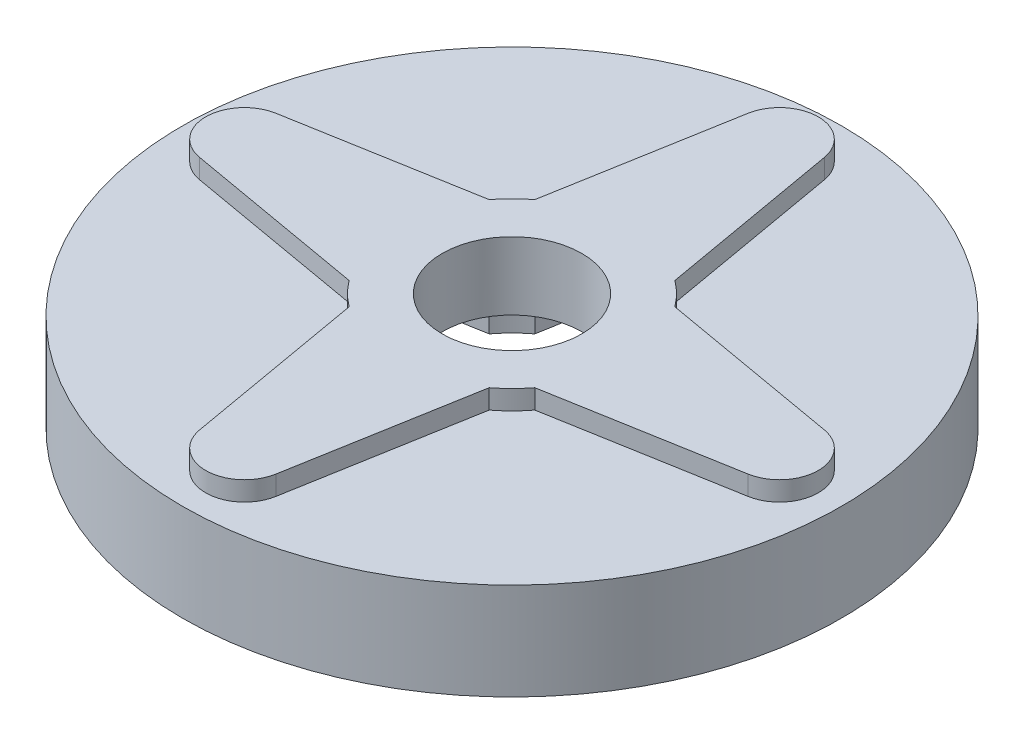
from build123d import *

# Parameters (mm, degrees)
SKETCH1_R           = 21.59
BOSS_EXTRUDE1_DEPTH = 6.35
SKETCH2_R           = 4.572
CUT_EXTRUDE1_DEPTH  = 7.35
SKETCH3_R           = 2.54
SKETCH3_R_2         = 7.62
SKETCH3_R_3         = 4.572
CUT_EXTRUDE2_DEPTH  = 3.175
SKETCH4_R           = 2.54
SKETCH4_R_2         = 7.62
SKETCH4_R_3         = 4.572
BOSS_EXTRUDE2_DEPTH = 1.27


with BuildPart() as part:
    # Sketch1 → Boss-Extrude1 (new body)
    with BuildSketch(Plane(origin=(0, 0, 0), x_dir=(1, 0, 0), z_dir=(0, 1, 0))):
        Circle(SKETCH1_R)
    extrude(amount=BOSS_EXTRUDE1_DEPTH)

    # Sketch2 → Cut-Extrude1 (cut, through all)
    with BuildSketch(Plane.XZ):
        Circle(SKETCH2_R)
    extrude(amount=-CUT_EXTRUDE1_DEPTH, mode=Mode.SUBTRACT)

    # Sketch3 → Cut-Extrude2 (cut)
    with BuildSketch(Plane.XZ):
        with BuildLine():
            ThreePointArc((4.587624646, -6.084250168), (0, -7.62), (-4.587624646, -6.084250168))
            Line((-4.587624646, -6.084250168), (-4.318, -7.62))
            Line((-4.318, -7.62), (-2.5017368, -17.965218605))
            ThreePointArc((-2.5017368, -17.965218605), (-0.220441067, -14.995583881), (2.54, -17.526))
            ThreePointArc((2.54, -17.526), (2.530416119, -17.746441067), (2.5017368, -17.965218605))
            Line((2.5017368, -17.965218605), (4.318, -7.62))
            Line((4.318, -7.62), (4.587624646, -6.084250168))
        make_face()
        with Locations((0, -17.526)):
            Circle(SKETCH3_R)
        with BuildLine():
            Line((-17.965218605, -2.5017368), (-7.62, -4.318))
            Line((-7.62, -4.318), (-6.084250168, -4.587624646))
            ThreePointArc((-6.084250168, -4.587624646), (-7.62, 0), (-6.084250168, 4.587624646))
            Line((-6.084250168, 4.587624646), (-7.62, 4.318))
            Line((-7.62, 4.318), (-17.965218605, 2.5017368))
            ThreePointArc((-17.965218605, 2.5017368), (-15.892600976, 1.94514977), (-14.986, 0))
            ThreePointArc((-14.986, 0), (-15.892600976, -1.94514977), (-17.965218605, -2.5017368))
        make_face()
        with Locations((-17.526, 0)):
            Circle(SKETCH3_R)
        Circle(SKETCH3_R_2)
        Circle(SKETCH3_R_3, mode=Mode.SUBTRACT)
        with BuildLine():
            Line((-4.318, 7.62), (-4.587624646, 6.084250168))
            ThreePointArc((-4.587624646, 6.084250168), (0, 7.62), (4.587624646, 6.084250168))
            Line((4.587624646, 6.084250168), (4.318, 7.62))
            Line((4.318, 7.62), (2.5017368, 17.965218605))
            ThreePointArc((2.5017368, 17.965218605), (2.530416119, 17.746441067), (2.54, 17.526))
            ThreePointArc((2.54, 17.526), (-0.220441067, 14.995583881), (-2.5017368, 17.965218605))
            Line((-2.5017368, 17.965218605), (-4.318, 7.62))
        make_face()
        with Locations((0, 17.526)):
            Circle(SKETCH3_R)
        with Locations((17.526, 0)):
            Circle(SKETCH3_R)
        with BuildLine():
            ThreePointArc((7.62, 0), (7.225869715, -2.418926799), (6.084250168, -4.587624646))
            Line((6.084250168, -4.587624646), (7.62, -4.318))
            Line((7.62, -4.318), (17.965218605, -2.5017368))
            ThreePointArc((17.965218605, -2.5017368), (14.986, 0), (17.965218605, 2.5017368))
            Line((17.965218605, 2.5017368), (7.62, 4.318))
            Line((7.62, 4.318), (6.084250168, 4.587624646))
            ThreePointArc((6.084250168, 4.587624646), (7.225869715, 2.418926799), (7.62, 0))
        make_face()
    extrude(amount=-CUT_EXTRUDE2_DEPTH, mode=Mode.SUBTRACT)

    # Sketch4 → Boss-Extrude2 (add)
    with BuildSketch(Plane(origin=(0, 6.35, 0), x_dir=(1, 0, 0), z_dir=(0, 1, 0))):
        with BuildLine():
            Line((4.318, 7.62), (2.5017368, 17.965218605))
            ThreePointArc((2.5017368, 17.965218605), (2.530416119, 17.746441067), (2.54, 17.526))
            ThreePointArc((2.54, 17.526), (-0.220441067, 14.995583881), (-2.5017368, 17.965218605))
            Line((-2.5017368, 17.965218605), (-4.318, 7.62))
            Line((-4.318, 7.62), (-4.587624646, 6.084250168))
            ThreePointArc((-4.587624646, 6.084250168), (0, 7.62), (4.587624646, 6.084250168))
            Line((4.587624646, 6.084250168), (4.318, 7.62))
        make_face()
        with Locations((0, 17.526)):
            Circle(SKETCH4_R)
        with BuildLine():
            Line((-7.62, -4.318), (-6.084250168, -4.587624646))
            ThreePointArc((-6.084250168, -4.587624646), (-7.62, 0), (-6.084250168, 4.587624646))
            Line((-6.084250168, 4.587624646), (-7.62, 4.318))
            Line((-7.62, 4.318), (-17.965218605, 2.5017368))
            ThreePointArc((-17.965218605, 2.5017368), (-15.892600976, 1.94514977), (-14.986, 0))
            ThreePointArc((-14.986, 0), (-15.892600976, -1.94514977), (-17.965218605, -2.5017368))
            Line((-17.965218605, -2.5017368), (-7.62, -4.318))
        make_face()
        with Locations((-17.526, 0)):
            Circle(SKETCH4_R)
        with Locations((0, -17.526)):
            Circle(SKETCH4_R)
        with BuildLine():
            Line((2.5017368, -17.965218605), (4.318, -7.62))
            Line((4.318, -7.62), (4.587624646, -6.084250168))
            ThreePointArc((4.587624646, -6.084250168), (0, -7.62), (-4.587624646, -6.084250168))
            Line((-4.587624646, -6.084250168), (-4.318, -7.62))
            Line((-4.318, -7.62), (-2.5017368, -17.965218605))
            ThreePointArc((-2.5017368, -17.965218605), (-0.220441067, -14.995583881), (2.54, -17.526))
            ThreePointArc((2.54, -17.526), (2.530416119, -17.746441067), (2.5017368, -17.965218605))
        make_face()
        with BuildLine():
            ThreePointArc((7.62, 0), (7.225869715, -2.418926799), (6.084250168, -4.587624646))
            Line((6.084250168, -4.587624646), (7.62, -4.318))
            Line((7.62, -4.318), (17.965218605, -2.5017368))
            ThreePointArc((17.965218605, -2.5017368), (14.986, 0), (17.965218605, 2.5017368))
            Line((17.965218605, 2.5017368), (7.62, 4.318))
            Line((7.62, 4.318), (6.084250168, 4.587624646))
            ThreePointArc((6.084250168, 4.587624646), (7.225869715, 2.418926799), (7.62, 0))
        make_face()
        with Locations((17.526, 0)):
            Circle(SKETCH4_R)
        Circle(SKETCH4_R_2)
        Circle(SKETCH4_R_3, mode=Mode.SUBTRACT)
    extrude(amount=BOSS_EXTRUDE2_DEPTH)


solid = part.part
